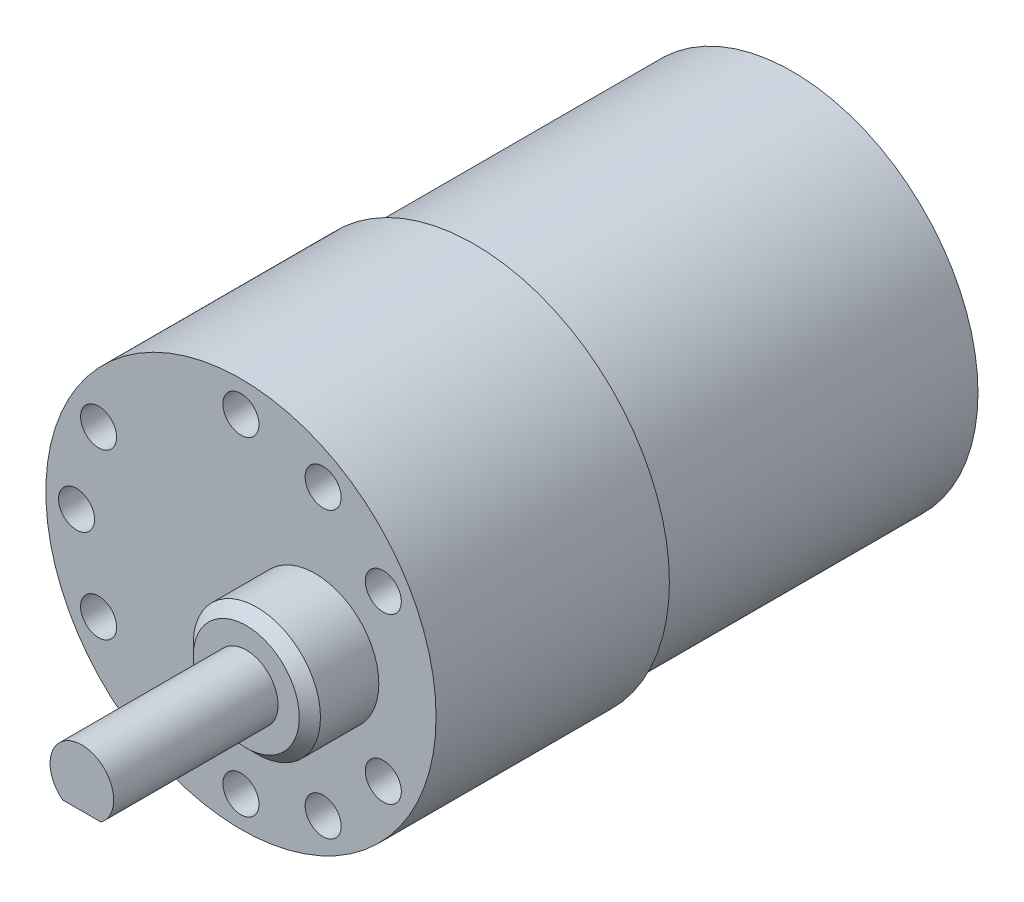
from build123d import *

# Parameters (mm, degrees)
SKETCH1_R           = 18.4
BOSS_EXTRUDE1_DEPTH = 22
SKETCH2_R           = 17.5
BOSS_EXTRUDE2_DEPTH = 30
SKETCH3_R           = 6
BOSS_EXTRUDE4_DEPTH = 6.5
CHAMFER1_SIZE       = 1
SKETCH4_R           = 3
BOSS_EXTRUDE5_DEPTH = 3.5
BOSS_EXTRUDE6_DEPTH = 12
SKETCH6_R           = 1.7
CUT_EXTRUDE1_DEPTH  = 12


with BuildPart() as part:
    # Sketch1 → Boss-Extrude1 (new body)
    with BuildSketch(Plane.XY):
        Circle(SKETCH1_R)
    extrude(amount=BOSS_EXTRUDE1_DEPTH)

    # Sketch2 → Boss-Extrude2 (add)
    with BuildSketch(Plane(origin=(0, 0, 0), x_dir=(-1, 0, 0), z_dir=(0, 0, -1))):
        Circle(SKETCH2_R)
    extrude(amount=BOSS_EXTRUDE2_DEPTH)

    # Sketch3 → Boss-Extrude4 (add)
    with BuildSketch(Plane.XY.offset(22)):
        with Locations((7, 0)):
            Circle(SKETCH3_R)
    extrude(amount=BOSS_EXTRUDE4_DEPTH)

    # Chamfer1
    chamfer1_edges = [part.edges().sort_by_distance(p)[0] for p in [
        (1, 0, 28.5),
    ]]
    chamfer(chamfer1_edges, length=CHAMFER1_SIZE)

    # Sketch4 → Boss-Extrude5 (add)
    with BuildSketch(Plane.XY.offset(28.5)):
        with Locations((7, 0)):
            Circle(SKETCH4_R)
    extrude(amount=BOSS_EXTRUDE5_DEPTH)

    # Sketch5 → Boss-Extrude6 (add)
    with BuildSketch(Plane.XY.offset(32)):
        with BuildLine():
            ThreePointArc((10, 0), (5.658359214, 2.683281573), (5.2, -2.4))
            Line((5.2, -2.4), (8.8, -2.4))
            ThreePointArc((8.8, -2.4), (9.683281573, -1.341640786), (10, 0))
        make_face()
    extrude(amount=BOSS_EXTRUDE6_DEPTH)

    # Sketch6 → Cut-Extrude1 (cut)
    with BuildSketch(Plane.XY.offset(22)):
        with Locations((0, 15.5)):
            Circle(SKETCH6_R)
        with Locations((13.423393759, 7.75)):
            Circle(SKETCH6_R)
        with Locations((13.423393759, -7.75)):
            Circle(SKETCH6_R)
        with Locations((0, -15.5)):
            Circle(SKETCH6_R)
        with Locations((-13.423393759, -7.75)):
            Circle(SKETCH6_R)
        with Locations((-13.423393759, 7.75)):
            Circle(SKETCH6_R)
        with Locations((-15.5, 0)):
            Circle(SKETCH6_R)
        with Locations((7.75, 13.423393759)):
            Circle(SKETCH6_R)
        with Locations((7.75, -13.423393759)):
            Circle(SKETCH6_R)
    extrude(amount=-CUT_EXTRUDE1_DEPTH, mode=Mode.SUBTRACT)


solid = part.part
